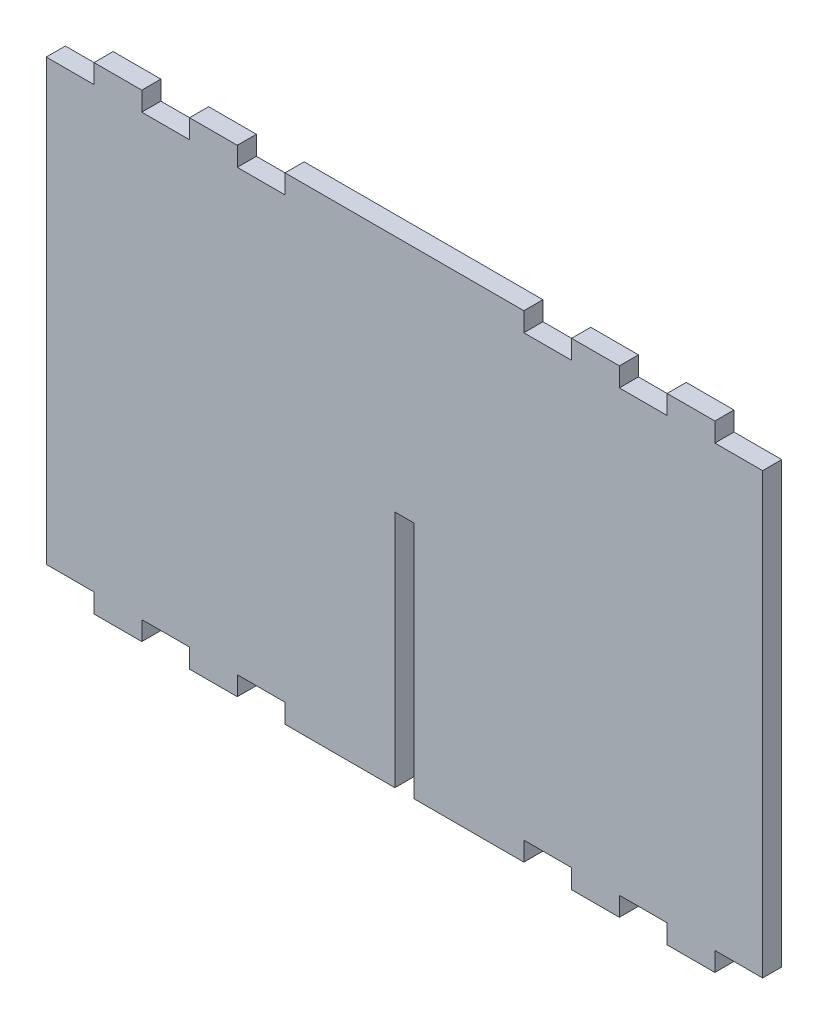
from build123d import *

# Parameters (mm, degrees)
SKETCH1_W           = 150
SKETCH1_H           = 100
BOSS_EXTRUDE1_DEPTH = 4
CUT_EXTRUDE2_START  = 4
SKETCH3_W           = 10
SKETCH3_H           = 4
SKETCH3_W_2         = 4
SKETCH3_H_2         = 50
CUT_EXTRUDE2_DEPTH  = 5


with BuildPart() as part:
    # Sketch1 → Boss-Extrude1 (new body)
    with BuildSketch(Plane.XY):
        Rectangle(SKETCH1_W, SKETCH1_H)
    extrude(amount=BOSS_EXTRUDE1_DEPTH)

    # Sketch3 → Cut-Extrude2 (cut, through all)
    with BuildSketch(Plane.XY.offset(CUT_EXTRUDE2_START)):
        with Locations((-50, 48)):
            Rectangle(SKETCH3_W, SKETCH3_H)
        with Locations((-30, 48)):
            Rectangle(SKETCH3_W, SKETCH3_H)
        with Locations((-70, 48)):
            Rectangle(SKETCH3_W, SKETCH3_H)
        with Locations((70, 48)):
            Rectangle(SKETCH3_W, SKETCH3_H)
        with Locations((50, 48)):
            Rectangle(SKETCH3_W, SKETCH3_H)
        with Locations((30, 48)):
            Rectangle(SKETCH3_W, SKETCH3_H)
        with Locations((50, -48)):
            Rectangle(SKETCH3_W, SKETCH3_H)
        with Locations((30, -48)):
            Rectangle(SKETCH3_W, SKETCH3_H)
        with Locations((70, -48)):
            Rectangle(SKETCH3_W, SKETCH3_H)
        with Locations((-70, -48)):
            Rectangle(SKETCH3_W, SKETCH3_H)
        with Locations((-50, -48)):
            Rectangle(SKETCH3_W, SKETCH3_H)
        with Locations((-30, -48)):
            Rectangle(SKETCH3_W, SKETCH3_H)
        with Locations((0, -25)):
            Rectangle(SKETCH3_W_2, SKETCH3_H_2)
    extrude(amount=-CUT_EXTRUDE2_DEPTH, mode=Mode.SUBTRACT)


solid = part.part
